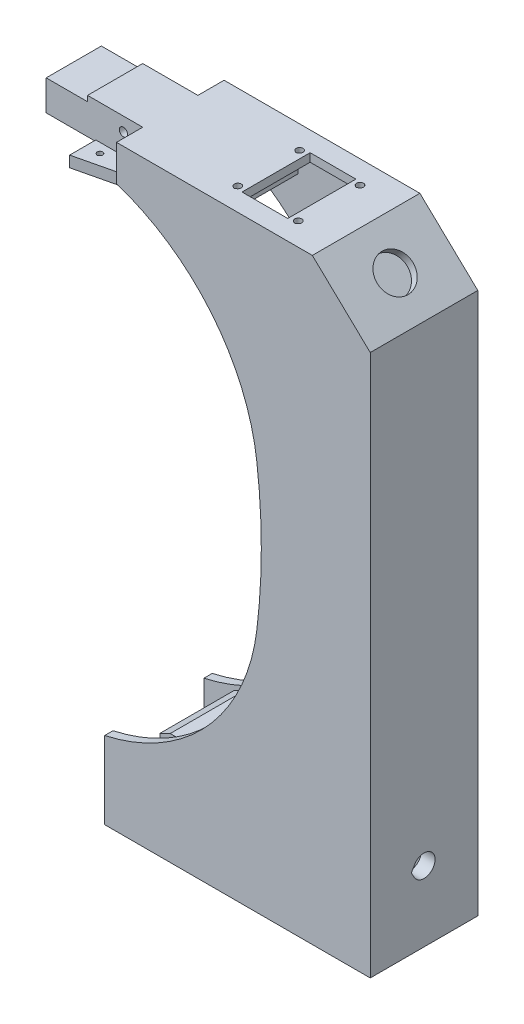
from build123d import *

# Parameters (mm, degrees)
EXTRUDE_6_DEPTH      = 39
CUT_EXTRUDE_START    = 3
CUT_EXTRUDE_2_DEPTH  = 33
EXTRUDE_START        = 9.5
SKETCH_7_W           = 35
SKETCH_7_H           = 13
EXTRUDE_7_DEPTH      = 20
EXTRUDE_START_2      = -16.5
EXTRUDE_8_DEPTH      = 4
CUT_EXTRUDE_START_2  = 180
CUT_EXTRUDE_3_DEPTH  = 10
SKETCH_13_R          = 1.5
CUT_EXTRUDE_4_DEPTH  = 30
SKETCH_14_W          = 15
SKETCH_14_H          = 2
CUT_EXTRUDE_5_DEPTH  = 30
CUT_EXTRUDE_START_3  = 17
CUT_EXTRUDE_7_DEPTH  = 85
CUT_EXTRUDE_START_4  = 13
CUT_EXTRUDE_9_DEPTH  = 5
SKETCH_20_W          = 16.6
SKETCH_20_H          = 24.7
CUT_EXTRUDE_10_DEPTH = 5
SKETCH_21_R          = 6.5
CUT_EXTRUDE_11_DEPTH = 5
CUT_EXTRUDE_12_DEPTH = 17
CUT_EXTRUDE_13_DEPTH = 3
CUT_EXTRUDE_START_5  = 30
CUT_EXTRUDE_14_DEPTH = 3
SKETCH_26_W          = 12.700381469
SKETCH_26_H          = 20
EXTRUDE_9_DEPTH      = 2
EXTRUDE_START_3      = 7
SKETCH_27_W          = 17
SKETCH_27_H          = 33
EXTRUDE_10_DEPTH     = 3


with BuildPart() as part:
    # Эскиз1 → Бобышка-Вытянуть6 (new body)
    with BuildSketch(Plane.XY):
        with BuildLine():
            Line((4.299618531, 175.402841826), (4.299618531, 188.402841826))
            Line((4.299618531, 188.402841826), (75.299618531, 188.402841826))
            Line((75.299618531, 188.402841826), (96.299618531, 168.402841826))
            Line((96.299618531, 168.402841826), (96.299619, 0))
            Line((96.299619, 0), (96.299619, -28))
            Line((96.299619, -28), (0, -28))
            Line((0, -28), (0, 0))
            ThreePointArc((0, 0), (37.229295141, 21.561020186), (55.173142182, 60.662380285))
            ThreePointArc((55.173142182, 60.662380285), (56.797307883, 87.162380285), (55.173142182, 113.662380285))
            ThreePointArc((55.173142182, 113.662380285), (38.726552267, 151.940422917), (4.299618531, 175.402841826))
        make_face()
    extrude(amount=EXTRUDE_6_DEPTH)

    # Эскиз5 → Вырез-Вытянуть2 (cut)
    with BuildSketch(Plane.XY.offset(CUT_EXTRUDE_START)):
        Polygon((34.099618531, 175.402841826), (4.299618531, 175.402841826), (4.299618531, 169.021888999), (-18.700381469, 169.021888999), (-18.700381469, -25), (14, -25), (14, 6.5), (30.299619, 6.5), (30.299619, -25), (91.299619, -25), (91.299619, 169.021888999), (74.099618531, 185.402841826), (34.099618531, 185.402841826), align=None)
    extrude(amount=CUT_EXTRUDE_2_DEPTH, mode=Mode.SUBTRACT)

    # Эскиз7 → Бобышка-Вытянуть7 (add)
    with BuildSketch(Plane.XY.offset(EXTRUDE_START)):
        with Locations((-13.200381469, 181.902841826)):
            Rectangle(SKETCH_7_W, SKETCH_7_H)
    extrude(amount=EXTRUDE_7_DEPTH)

    # Эскиз22 → Бобышка-Вытянуть8 (add)
    with BuildSketch(Plane(origin=(0, 188.402841826, 0), x_dir=(1, 0, 0), z_dir=(0, 1, 0)).offset(EXTRUDE_START_2)):
        Polygon((10.299618531, -29.5), (10.299618531, -33.5375), (-12.700381469, -39), (-12.700381469, -29.5), align=None)
        Polygon((-12.700381469, -9.5), (-12.700381469, 0), (10.299618531, -5.4625), (10.299618531, -9.5), align=None)
    extrude(amount=EXTRUDE_8_DEPTH)

    # Эскиз12 → Вырез-Вытянуть3 (cut)
    with BuildSketch(Plane(origin=(0, 0, 0), x_dir=(1, 0, 0), z_dir=(0, 1, 0)).offset(CUT_EXTRUDE_START_2)):
        with BuildLine():
            Line((-7.700381469, -34.154700538), (-7.200381469, -33.866025404))
            ThreePointArc((-7.200381469, -33.866025404), (-7.700381469, -32), (-8.200381469, -33.866025404))
            Line((-8.200381469, -33.866025404), (-7.700381469, -34.154700538))
        make_face()
        with BuildLine():
            Line((-7.700381469, -7.154700538), (-7.200381469, -6.866025404))
            ThreePointArc((-7.200381469, -6.866025404), (-7.700381469, -5), (-8.200381469, -6.866025404))
            Line((-8.200381469, -6.866025404), (-7.700381469, -7.154700538))
        make_face()
    extrude(amount=-CUT_EXTRUDE_3_DEPTH, mode=Mode.SUBTRACT)

    # Эскиз13 → Вырез-Вытянуть4 (cut)
    with BuildSketch(Plane.XY):
        with Locations((-2.700381469, 183.402841826)):
            Circle(SKETCH_13_R)
    extrude(amount=CUT_EXTRUDE_4_DEPTH, mode=Mode.SUBTRACT)

    # Эскиз14 → Вырез-Вытянуть5 (cut)
    with BuildSketch(Plane.XY):
        with Locations((-23.200381469, 187.402841826)):
            Rectangle(SKETCH_14_W, SKETCH_14_H)
    extrude(amount=CUT_EXTRUDE_5_DEPTH, mode=Mode.SUBTRACT)

    # Эскиз17 → Вырез-Вытянуть7 (cut)
    with BuildSketch(Plane(origin=(0, 0, 0), x_dir=(0, 0, -1), z_dir=(1, 0, 0)).offset(CUT_EXTRUDE_START_3)):
        with BuildLine():
            Line((-24.118802154, -2.5), (-22.964101615, -0.5))
            ThreePointArc((-22.964101615, -0.5), (-15.5, -2.5), (-22.964101615, -4.5))
            Line((-22.964101615, -4.5), (-24.118802154, -2.5))
        make_face()
    extrude(amount=CUT_EXTRUDE_7_DEPTH, mode=Mode.SUBTRACT)

    # Эскиз18 → Вырез-Вытянуть9 (cut)
    with BuildSketch(Plane(origin=(0, 0, 0), x_dir=(0, 0, -1), z_dir=(1, 0, 0)).offset(CUT_EXTRUDE_START_4)):
        with BuildLine():
            Line((-21.809401077, -2.5), (-21.232050808, -1.5))
            ThreePointArc((-21.232050808, -1.5), (-17.5, -2.5), (-21.232050808, -3.5))
            Line((-21.232050808, -3.5), (-21.809401077, -2.5))
        make_face()
    extrude(amount=CUT_EXTRUDE_9_DEPTH, mode=Mode.SUBTRACT)

    # Эскиз20 → Вырез-Вытянуть10 (cut)
    with BuildSketch(Plane(origin=(0, 188.402841826, 0), x_dir=(1, 0, 0), z_dir=(0, 1, 0))):
        with Locations((50.95, -19.5)):
            Rectangle(SKETCH_20_W, SKETCH_20_H)
        with BuildLine():
            Line((40, -32.143375673), (40.625, -31.782531755))
            ThreePointArc((40.625, -31.782531755), (40, -29.45), (39.375, -31.782531755))
            Line((39.375, -31.782531755), (40, -32.143375673))
        make_face()
        with BuildLine():
            Line((40, -9.743375673), (40.625, -9.382531755))
            ThreePointArc((40.625, -9.382531755), (40, -7.05), (39.375, -9.382531755))
            Line((39.375, -9.382531755), (40, -9.743375673))
        make_face()
        with BuildLine():
            Line((61.9, -9.743375673), (62.525, -9.382531755))
            ThreePointArc((62.525, -9.382531755), (61.9, -7.05), (61.275, -9.382531755))
            Line((61.275, -9.382531755), (61.9, -9.743375673))
        make_face()
        with BuildLine():
            Line((61.9, -32.143375673), (62.525, -31.782531755))
            ThreePointArc((62.525, -31.782531755), (61.9, -29.45), (61.275, -31.782531755))
            Line((61.275, -31.782531755), (61.9, -32.143375673))
        make_face()
    extrude(amount=-CUT_EXTRUDE_10_DEPTH, mode=Mode.SUBTRACT)

    # Эскиз21 → Вырез-Вытянуть11 (cut)
    with BuildSketch(Plane(origin=(129.903734815, 136.398921556, 0), x_dir=(0, 0, -1), z_dir=(0.689655172, 0.724137931, 0))):
        with Locations((-19.5, 60.905684392)):
            Circle(SKETCH_21_R)
    extrude(amount=-CUT_EXTRUDE_11_DEPTH, mode=Mode.SUBTRACT)

    # Эскиз23 → Вырез-Вытянуть12 (cut)
    with BuildSketch(Plane.ZY.offset(-14)):
        with BuildLine():
            Line((22.964101615, -17), (22.098076211, -15.5))
            ThreePointArc((22.098076211, -15.5), (16.5, -17), (22.098076211, -18.5))
            Line((22.098076211, -18.5), (22.964101615, -17))
        make_face()
    extrude(amount=-CUT_EXTRUDE_12_DEPTH, mode=Mode.SUBTRACT)

    # Эскиз24 → Вырез-Вытянуть13 (cut)
    with BuildSketch(Plane.XY.offset(3)):
        Polygon((11, -1), (27.169940805, 6.907781886), (23.655371078, 14.094422244), (7.485430273, 6.186640358), align=None)
    extrude(amount=CUT_EXTRUDE_13_DEPTH, mode=Mode.SUBTRACT)

    # Эскиз25 → Вырез-Вытянуть14 (cut)
    with BuildSketch(Plane.XY.offset(3).offset(CUT_EXTRUDE_START_5)):
        Polygon((11, -1), (27.169940805, 6.907781886), (23.655371078, 14.094422244), (7.485430273, 6.186640358), align=None)
    extrude(amount=CUT_EXTRUDE_14_DEPTH, mode=Mode.SUBTRACT)

    # Эскиз26 → Бобышка-Вытянуть9 (add)
    with BuildSketch(Plane.XZ.offset(-175.402841826)):
        with Locations((-6.350190735, 19.5)):
            Rectangle(SKETCH_26_W, SKETCH_26_H)
    extrude(amount=EXTRUDE_9_DEPTH)

    # Эскиз27 → Бобышка-Вытянуть10 (add)
    with BuildSketch(Plane(origin=(127.834769298, 134.226507763, 0), x_dir=(0.724137931, -0.689655172, 0), z_dir=(-0.689655172, -0.724137931, 0)).offset(EXTRUDE_START_3)):
        with Locations((-58.953302792, 19.5)):
            Rectangle(SKETCH_27_W, SKETCH_27_H)
    extrude(amount=EXTRUDE_10_DEPTH)


solid = part.part
